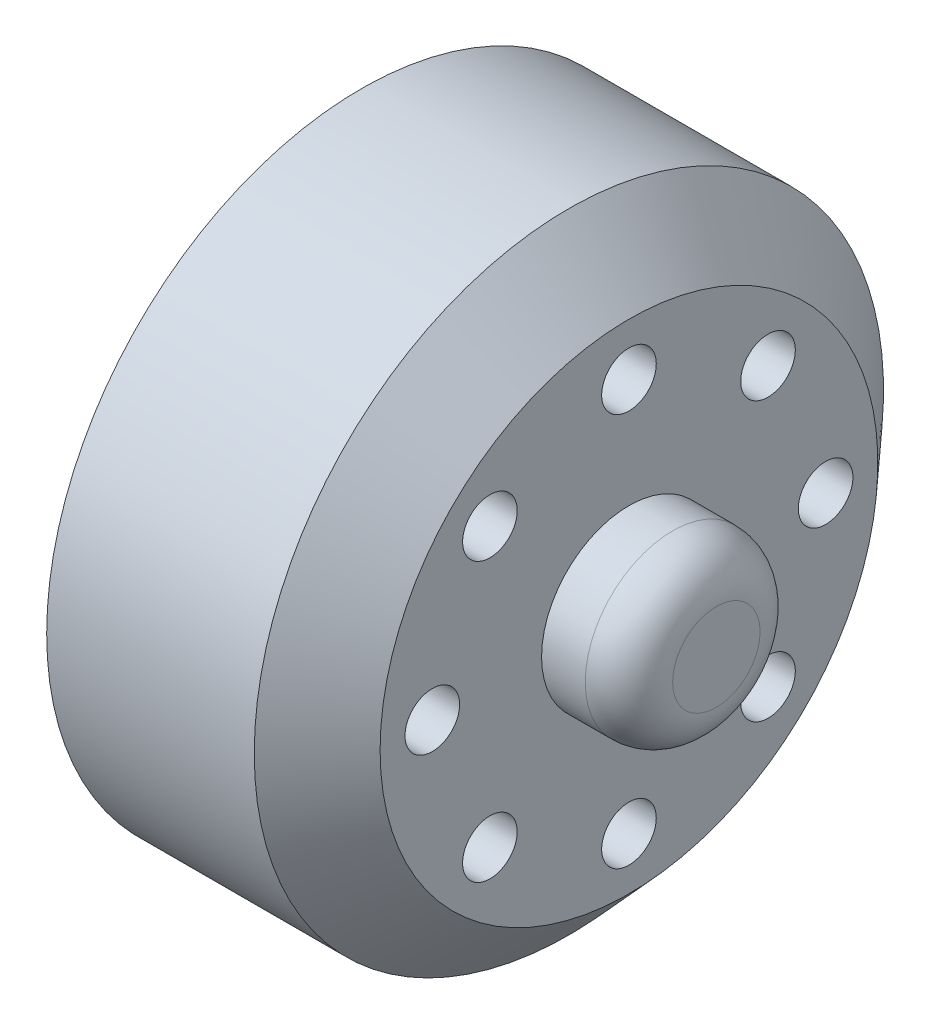
from build123d import *

# Parameters (mm, degrees)
FILLET1_R          = 2
SKETCH2_R          = 1.25
CUT_EXTRUDE1_DEPTH = 12.25
SKETCH3_R          = 2.5
CUT_EXTRUDE2_DEPTH = 7.25


with BuildPart() as part:
    # Sketch1 → Revolve1 (revolve)
    with BuildSketch(Plane(origin=(0, 0, 0), x_dir=(1, 0, 0), z_dir=(0, 1, 0))):
        Polygon((-1.630434783, 14.4), (7.869565217, 14.4), (10.619565217, 11.390476118), (10.619565217, 4), (14.619565217, 4), (14.619565217, 0), (13.372742768, 0), (3.071692396, 0), (3.071692396, 5.7), (-1.630434783, 5.7), align=None)
    revolve(axis=Axis((-12.391304348, 0, 0), (1, 0, 0)))

    # Fillet1
    fillet1_edges = [part.edges().sort_by_distance(p)[0] for p in [
        (14.619565217, 0, 4),
    ]]
    fillet(fillet1_edges, radius=FILLET1_R)

    # Sketch2 → Cut-Extrude1 (cut)
    with BuildSketch(Plane(origin=(10.619565217, 0, 0), x_dir=(0, 0, -1), z_dir=(1, 0, 0))):
        with Locations((0, 9)):
            Circle(SKETCH2_R)
        with Locations((6.363961031, 6.363961031)):
            Circle(SKETCH2_R)
        with Locations((9, 0)):
            Circle(SKETCH2_R)
        with Locations((6.363961031, -6.363961031)):
            Circle(SKETCH2_R)
        with Locations((0, -9)):
            Circle(SKETCH2_R)
        with Locations((-6.363961031, -6.363961031)):
            Circle(SKETCH2_R)
        with Locations((-9, 0)):
            Circle(SKETCH2_R)
        with Locations((-6.363961031, 6.363961031)):
            Circle(SKETCH2_R)
    extrude(amount=-CUT_EXTRUDE1_DEPTH, mode=Mode.SUBTRACT)

    # Sketch3 → Cut-Extrude2 (cut)
    with BuildSketch(Plane.ZY.offset(1.630434783)):
        with Locations((0, 9)):
            Circle(SKETCH3_R)
        with Locations((6.363961031, 6.363961031)):
            Circle(SKETCH3_R)
        with Locations((9, 0)):
            Circle(SKETCH3_R)
        with Locations((6.363961031, -6.363961031)):
            Circle(SKETCH3_R)
        with Locations((0, -9)):
            Circle(SKETCH3_R)
        with Locations((-6.363961031, -6.363961031)):
            Circle(SKETCH3_R)
        with Locations((-9, 0)):
            Circle(SKETCH3_R)
        with Locations((-6.363961031, 6.363961031)):
            Circle(SKETCH3_R)
    extrude(amount=-CUT_EXTRUDE2_DEPTH, mode=Mode.SUBTRACT)


solid = part.part
